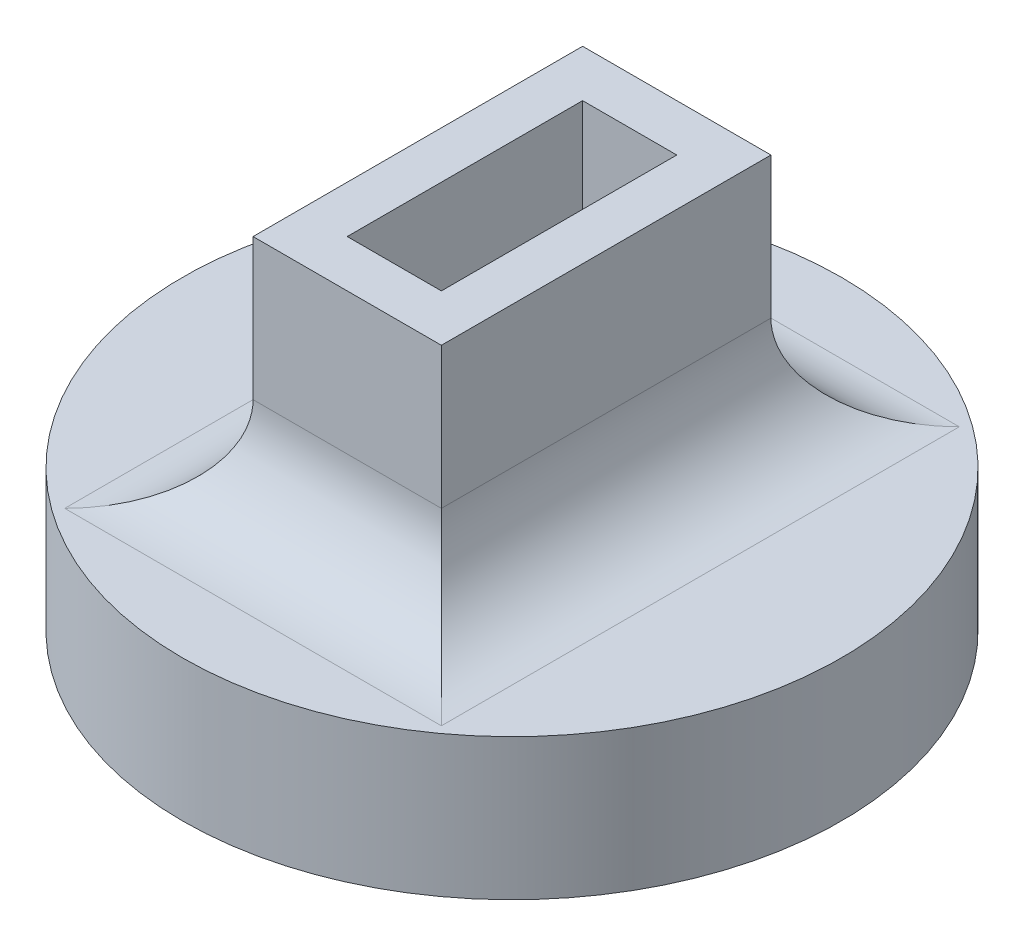
from build123d import *

# Parameters (mm, degrees)
SKETCH1_R           = 7
BOSS_EXTRUDE1_DEPTH = 3
SKETCH2_W           = 4
SKETCH2_H           = 7
SKETCH2_W_2         = 2
SKETCH2_H_2         = 5
BOSS_EXTRUDE2_DEPTH = 5
FILLET1_R           = 2


with BuildPart() as part:
    # Sketch1 → Boss-Extrude1 (new body)
    with BuildSketch(Plane(origin=(0, 0, 0), x_dir=(1, 0, 0), z_dir=(0, 1, 0))):
        Circle(SKETCH1_R)
    extrude(amount=BOSS_EXTRUDE1_DEPTH)

    # Sketch2 → Boss-Extrude2 (add)
    with BuildSketch(Plane(origin=(0, 3, 0), x_dir=(1, 0, 0), z_dir=(0, 1, 0))):
        Rectangle(SKETCH2_W, SKETCH2_H)
        Rectangle(SKETCH2_W_2, SKETCH2_H_2, mode=Mode.SUBTRACT)
    extrude(amount=BOSS_EXTRUDE2_DEPTH)

    # Fillet1
    fillet1_edges = [part.edges().sort_by_distance(p)[0] for p in [
        (-2, 3, 0),
        (0, 3, -3.5),
        (2, 3, 0),
        (0, 3, 3.5),
    ]]
    fillet(fillet1_edges, radius=FILLET1_R)


solid = part.part
